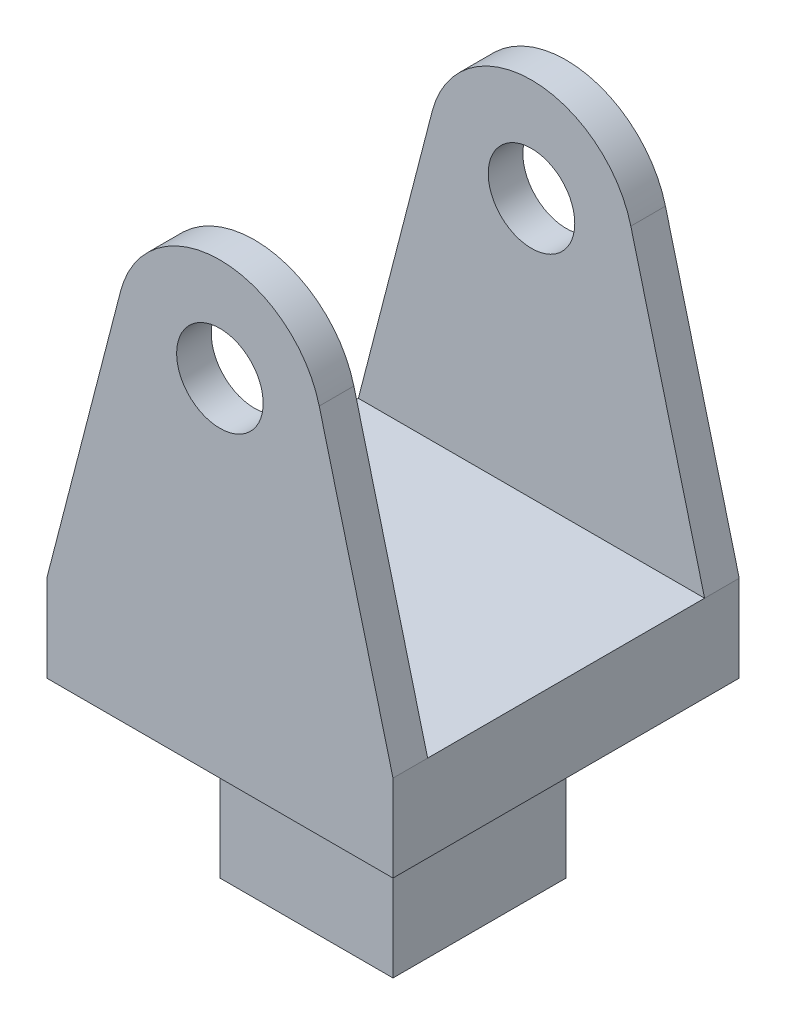
from build123d import *

# Parameters (mm, degrees)
SKETCH3_W           = 20
SKETCH3_H           = 20
BOSS_EXTRUDE1_DEPTH = 30
SKETCH4_W           = 16
SKETCH4_H           = 25
CUT_EXTRUDE1_DEPTH  = 26
SKETCH7_R           = 2.5
CUT_EXTRUDE2_DEPTH  = 16.5
CUT_EXTRUDE3_DEPTH  = 33
SKETCH9_W           = 10
SKETCH9_H           = 10
BOSS_EXTRUDE2_DEPTH = 10


with BuildPart() as part:
    # Sketch3 → Boss-Extrude1 (new body)
    with BuildSketch(Plane(origin=(0, 0, 0), x_dir=(1, 0, 0), z_dir=(0, 1, 0))):
        Rectangle(SKETCH3_W, SKETCH3_H)
    extrude(amount=BOSS_EXTRUDE1_DEPTH)

    # Sketch4 → Cut-Extrude1 (cut)
    with BuildSketch(Plane.ZY.offset(10)):
        with Locations((0, 17.5)):
            Rectangle(SKETCH4_W, SKETCH4_H)
    extrude(amount=-CUT_EXTRUDE1_DEPTH, mode=Mode.SUBTRACT)

    # Sketch7 → Cut-Extrude2 (cut, symmetric)
    with BuildSketch(Plane.XY):
        with Locations((0, 20)):
            Circle(SKETCH7_R)
    extrude(amount=CUT_EXTRUDE2_DEPTH, both=True, mode=Mode.SUBTRACT)

    # Sketch8 → Cut-Extrude3 (cut)
    with BuildSketch(Plane.XY.offset(10)):
        with BuildLine():
            Line((-10, 5), (-5.739080816, 21.483527122))
            ThreePointArc((-5.739080816, 21.483527122), (0, 25.927723116), (5.739080816, 21.483527122))
            Line((5.739080816, 21.483527122), (10, 5))
            Line((10, 5), (10, 30))
            Line((10, 30), (-10, 30))
            Line((-10, 30), (-10, 5))
        make_face()
    extrude(amount=-CUT_EXTRUDE3_DEPTH, mode=Mode.SUBTRACT)

    # Sketch9 → Boss-Extrude2 (add)
    with BuildSketch(Plane.XZ):
        Rectangle(SKETCH9_W, SKETCH9_H)
    extrude(amount=BOSS_EXTRUDE2_DEPTH)


solid = part.part
